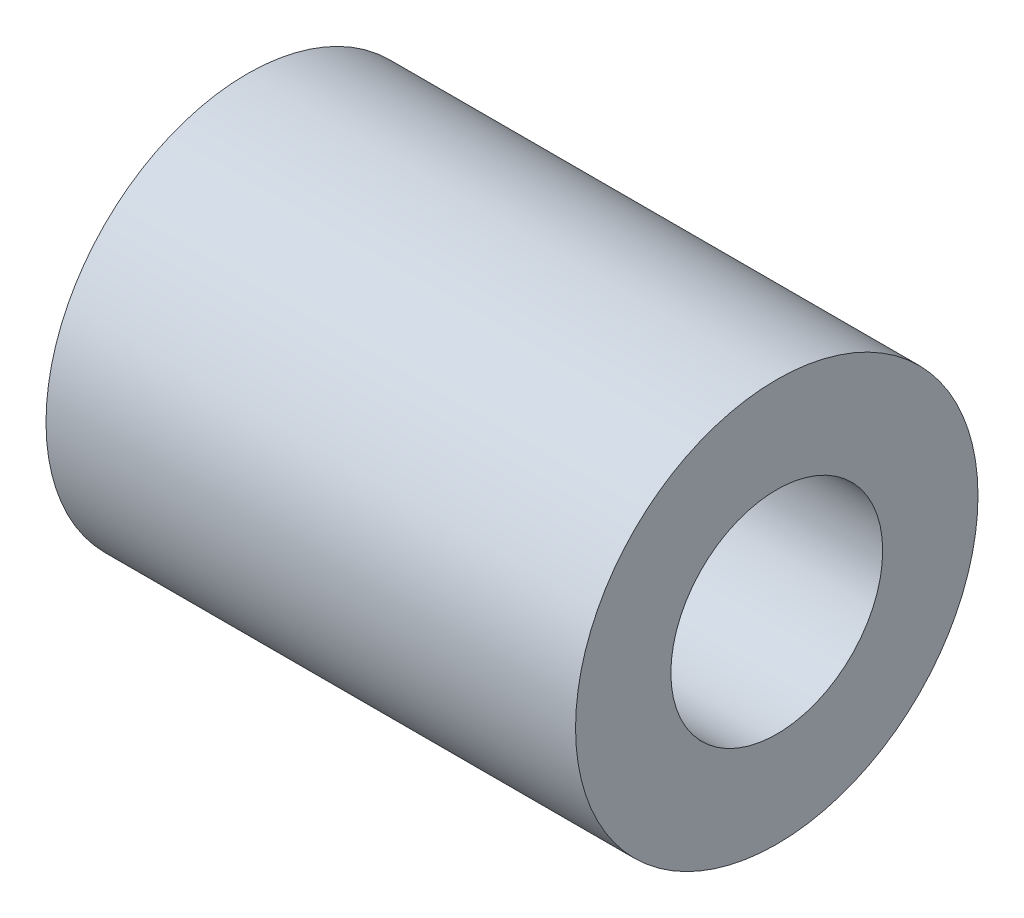
from build123d import *


with BuildPart() as part:
    # Skizze2 → Rotation1 (revolve)
    with BuildSketch(Plane.XY):
        Polygon((0, 2.5), (0, 9.5), (25, 9.5), (25, 5), (12.5, 5), (12.5, 2.5), align=None)
    revolve(axis=Axis((0, 0, 0), (1, 0, 0)))


solid = part.part
